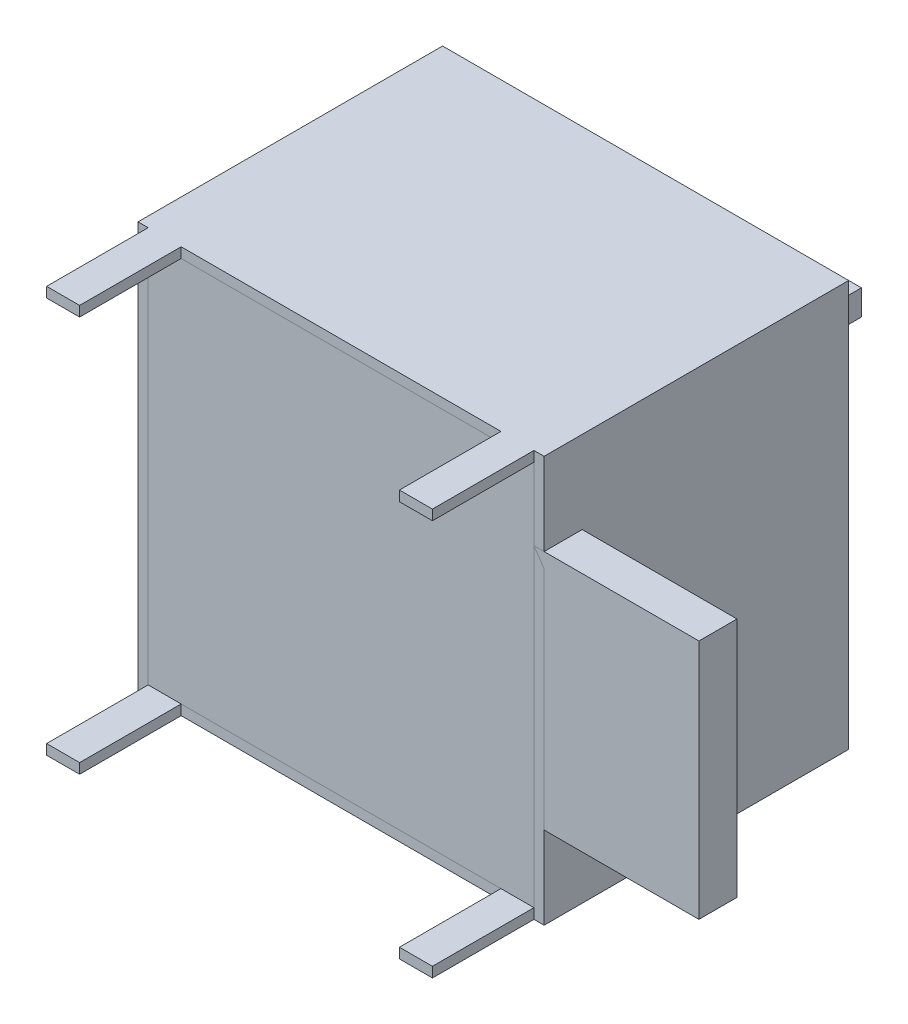
from build123d import *

# Parameters (mm, degrees)
SKETCH_1_W               = 16
SKETCH_1_H               = 16
EXTRUDE_1_DEPTH          = 12
SHELL_1_T                = -0.4
SKETCH_2_W               = 1.3
SKETCH_2_H               = 0.4
EXTRUDE_2_DEPTH          = 4
MIRROR_2_COPY_1_SKETCH_W = 1.3
MIRROR_2_COPY_1_SKETCH_H = 0.4
MIRROR_2_COPY_1_DEPTH    = 4
MIRROR_2_COPY_2_SKETCH_W = 1.3
MIRROR_2_COPY_2_SKETCH_H = 0.4
MIRROR_2_COPY_2_DEPTH    = 4
EXTRUDE_3_DEPTH          = 1.5
SKETCH_4_W               = 2
SKETCH_4_H               = 1
EXTRUDE_4_DEPTH          = 7.5


with BuildPart() as part:
    # 스케치1 → 보스-돌출1 (new body)
    with BuildSketch(Plane.XY):
        with Locations((8, 8)):
            Rectangle(SKETCH_1_W, SKETCH_1_H)
    extrude(amount=EXTRUDE_1_DEPTH)

    # 쉘1
    shell_1_openings = [part.faces().sort_by_distance(p)[0] for p in [
        (8, 8, 12),
    ]]
    offset(amount=SHELL_1_T, openings=shell_1_openings, kind=Kind.INTERSECTION)

    # 스케치2 → 보스-돌출2 (add)
    with BuildSketch(Plane.XY.offset(12)):
        with Locations((1.05, 15.8)):
            Rectangle(SKETCH_2_W, SKETCH_2_H)
    extrude_2 = extrude(amount=EXTRUDE_2_DEPTH)

    # 대칭 복사1: 보스-돌출2 across plane
    add(extrude_2.mirror(Plane(origin=(8, 0, 0), x_dir=(0, 0, 1), z_dir=(1, 0, 0))))

    # 대칭 복사2 copy 1 sketch → 대칭 복사2 copy 1 (add)
    with BuildSketch(Plane(origin=(16, 16, 12), x_dir=(-1, 0, 0), z_dir=(0, 0, 1))):
        with Locations((1.05, 15.8)):
            Rectangle(MIRROR_2_COPY_1_SKETCH_W, MIRROR_2_COPY_1_SKETCH_H)
    extrude(amount=MIRROR_2_COPY_1_DEPTH)

    # 대칭 복사2 copy 2 sketch → 대칭 복사2 copy 2 (add)
    with BuildSketch(Plane(origin=(0, 16, 12), x_dir=(1, 0, 0), z_dir=(0, 0, 1))):
        with Locations((1.05, -15.8)):
            Rectangle(MIRROR_2_COPY_2_SKETCH_W, MIRROR_2_COPY_2_SKETCH_H)
    extrude(amount=MIRROR_2_COPY_2_DEPTH)

    # 스케치4 → 보스-돌출4 (add)
    with BuildSketch(Plane(origin=(0, 0, 0), x_dir=(-1, 0, 0), z_dir=(0, 0, -1))):
        with Locations((-8, 8)):
            Rectangle(SKETCH_4_W, SKETCH_4_H)
    extrude(amount=EXTRUDE_4_DEPTH)


with BuildPart() as body_2:
    # 스케치3 → 보스-돌출3 (new body)
    with BuildSketch(Plane.XY.offset(12)):
        Polygon((0.4, 15.6), (15.6, 15.6), (15.6, 12.75), (22.1, 12.75), (22.1, 3.25), (15.6, 3.25), (15.6, 0.4), (0.4, 0.4), align=None)
    extrude(amount=-EXTRUDE_3_DEPTH)


solid = Compound([part.part, body_2.part])
